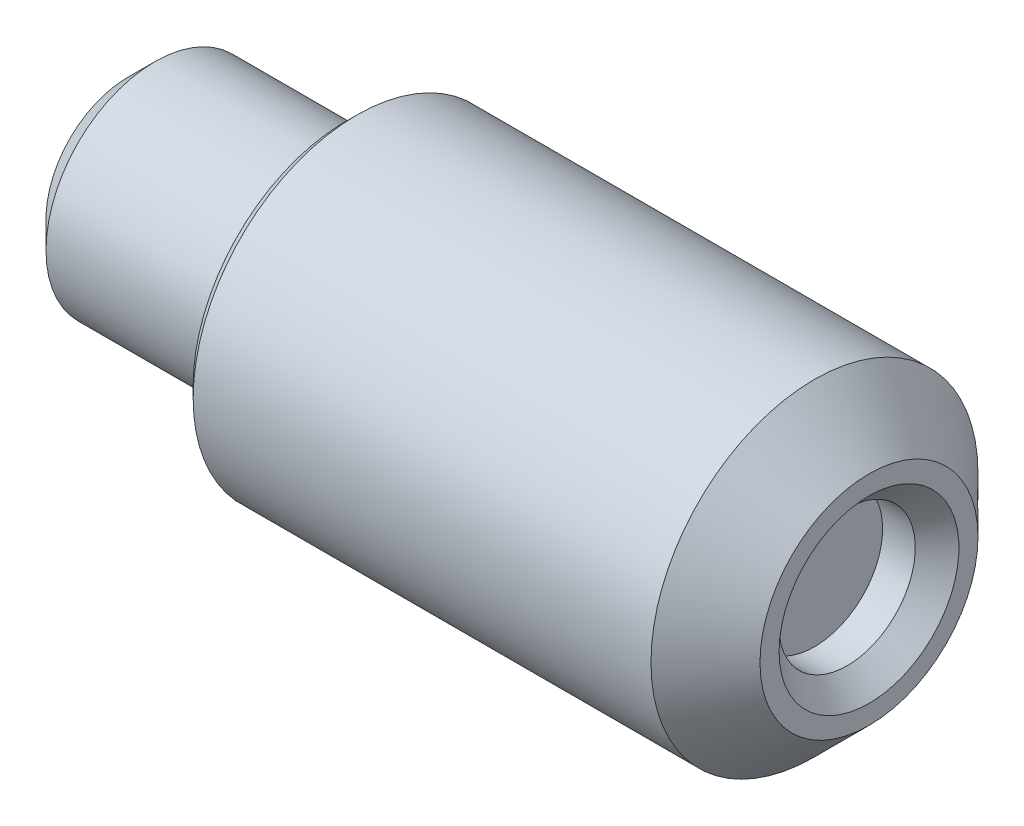
from build123d import *

# Parameters (mm, degrees)
CHANFREIN2_SIZE = 1
CHANFREIN3_SIZE = 0.4
CHANFREIN4_SIZE = 0.2
CHANFREIN5_SIZE = 0.5


with BuildPart() as part:
    # Esquisse1 → Révolution1 (revolve)
    with BuildSketch(Plane.XY, mode=Mode.PRIVATE) as r_volution1_sk:
        Polygon((-1, 0), (-1, 1.25), (0, 1.25), (0, 3), (-9.6, 3), (-9.6, 2), (-13.6, 2), (-13.6, 0), align=None)
    revolve(r_volution1_sk.sketch.rotate(Axis((0, 0, 0), (1, 0, 0)), 90), axis=Axis((0, 0, 0), (1, 0, 0)))  # turned: the seam where the file's is

    # Chanfrein2
    chanfrein2_edges = [part.edges().sort_by_distance(p)[0] for p in [
        (0, 0, -3),
    ]]
    chamfer(chanfrein2_edges, length=CHANFREIN2_SIZE)

    # Chanfrein3
    chanfrein3_edges = [part.edges().sort_by_distance(p)[0] for p in [
        (0, 0, -1.25),
    ]]
    chamfer(chanfrein3_edges, length=CHANFREIN3_SIZE)

    # Chanfrein4
    chanfrein4_edges = [part.edges().sort_by_distance(p)[0] for p in [
        (-9.6, 0, -3),
    ]]
    chamfer(chanfrein4_edges, length=CHANFREIN4_SIZE)

    # Chanfrein5
    chanfrein5_edges = [part.edges().sort_by_distance(p)[0] for p in [
        (-13.6, 0, -2),
    ]]
    chamfer(chanfrein5_edges, length=CHANFREIN5_SIZE)


solid = part.part
